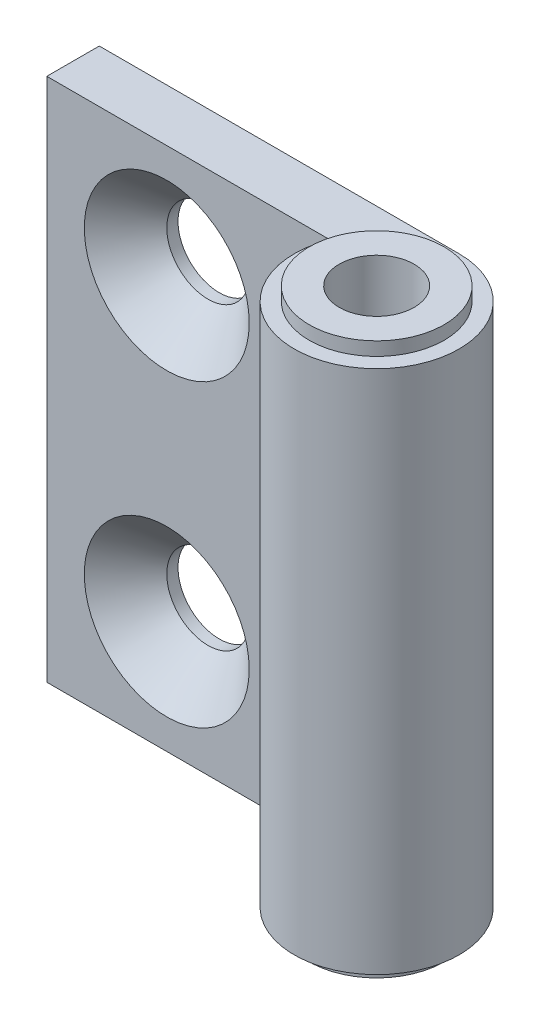
from build123d import *

# Parameters (mm, degrees)
EXTRUDE1_DEPTH      = 35
SKETCH2_W           = 4.5
SKETCH2_H           = 0.9
SKETCH3_W           = 4.5
SKETCH3_H           = 0.9
HOLEWZD1_AT_2_COUNT = 2
HOLEWZD1_AT_2_PITCH = 20
HOLEWZD2_D          = 5
HOLEWZD2_DEPTH      = 36.8


with BuildPart() as part:
    # Sketch1 → Extrude1 (new body)
    with BuildSketch(Plane(origin=(0, 35.9, 0), x_dir=(1, 0, 0), z_dir=(0, 1, 0))):
        with BuildLine():
            Line((-24, 5.5), (-24, 2))
            Line((-24, 2), (-5.123475383, 2))
            ThreePointArc((-5.123475383, 2), (3.102418411, -4.541475531), (0, 5.5))
            Line((0, 5.5), (-24, 5.5))
        make_face()
    extrude(amount=-EXTRUDE1_DEPTH)

    # Sketch2 → Revolve1 (revolve)
    with BuildSketch(Plane.XY):
        with Locations((2.25, 0.45)):
            Rectangle(SKETCH2_W, SKETCH2_H)
    revolve(axis=Axis((0, 0.9, 0), (0, -1, 0)))

    # Sketch3 → Revolve2 (revolve)
    with BuildSketch(Plane.XY):
        with Locations((2.25, 36.35)):
            Rectangle(SKETCH3_W, SKETCH3_H)
    revolve(axis=Axis((0, 36.8, 0), (0, -1, 0)))

    # Sketch4 → HoleWzd1 (revolve, cut)
    with BuildSketch(Plane(origin=(-16, 28.4, -2), x_dir=(0, -1, 0), z_dir=(1, 0, 0))):
        Polygon((0, 0), (0, 3.5), (2.75, 3.5), (2.75, 2.75), (5.5, 0), align=None)
    holewzd1 = revolve(axis=Axis((-16, 28.4, 4.35), (0, 0, -1)), mode=Mode.SUBTRACT)

    # HoleWzd1 at 2: HoleWzd1 ×2
    with Locations(*[(0, -i * HOLEWZD1_AT_2_PITCH, 0) for i in range(1, HOLEWZD1_AT_2_COUNT)]):
        add(holewzd1, mode=Mode.SUBTRACT)

    # HoleWzd2
    with Locations(Plane(origin=(0, 36.8, 0), x_dir=(1, 0, 0), z_dir=(0, 1, 0))):
        with Locations((0, 0)):
            Hole(HOLEWZD2_D / 2, depth=HOLEWZD2_DEPTH)


solid = part.part
